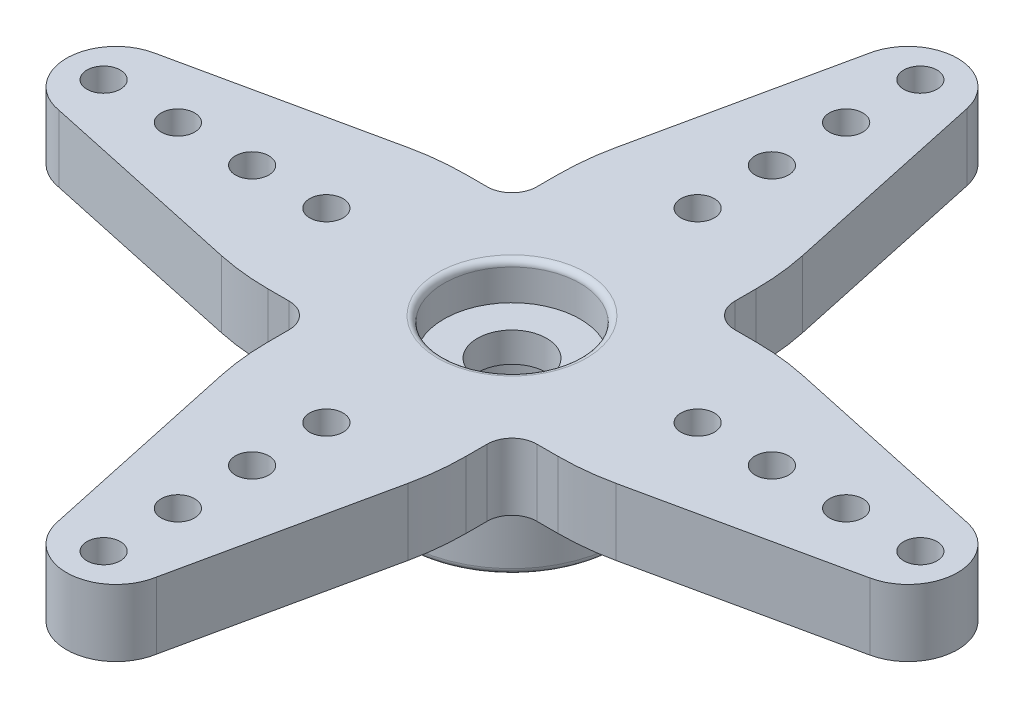
from build123d import *

# Parameters (mm, degrees)
ESQUISSE1_R             = 1.4
ESQUISSE1_R_2           = 0.675
BOSS_EXTRU_1_DEPTH      = 2.7
ESQUISSE2_R             = 2.75
ENL_V_MAT_EXTRU_1_DEPTH = 1.5
ESQUISSE3_R             = 4.4
ESQUISSE3_R_2           = 2.75
BOSS_EXTRU_2_DEPTH      = 3.3
CONG_1_R                = 0.25


with BuildPart() as part:
    # Esquisse1 → Boss.-Extru.1 (new body)
    with BuildSketch(Plane(origin=(0, 0, 0), x_dir=(1, 0, 0), z_dir=(0, 1, 0))):
        with BuildLine():
            Line((-4, 5.86229381), (-4, 5))
            ThreePointArc((-4, 5), (-4.292893219, 4.292893219), (-5, 4))
            Line((-5, 4), (-5.863381493, 4))
            ThreePointArc((-5.863381493, 4), (-6.922217369, 3.943785325), (-7.969148823, 3.775773317))
            Line((-7.969148823, 3.775773317), (-16.421153466, 1.955154663))
            ThreePointArc((-16.421153466, 1.955154663), (-17.999482643, -0.04548802), (-16.331804641, -1.972284381))
            Line((-16.331804641, -1.972284381), (-7.970163814, -3.77532015))
            ThreePointArc((-7.970163814, -3.77532015), (-6.922199111, -3.943671392), (-5.86229381, -4))
            Line((-5.86229381, -4), (-5, -4))
            ThreePointArc((-5, -4), (-4.292893219, -4.292893219), (-4, -5))
            Line((-4, -5), (-4, -5.863381493))
            ThreePointArc((-4, -5.863381493), (-3.943785325, -6.922217369), (-3.775773317, -7.969148823))
            Line((-3.775773317, -7.969148823), (-1.955154663, -16.421153466))
            ThreePointArc((-1.955154663, -16.421153466), (0.04548802, -17.999482643), (1.972284381, -16.331804641))
            Line((1.972284381, -16.331804641), (3.77532015, -7.970163814))
            ThreePointArc((3.77532015, -7.970163814), (3.943671392, -6.922199111), (4, -5.86229381))
            Line((4, -5.86229381), (4, -5))
            ThreePointArc((4, -5), (4.292893219, -4.292893219), (5, -4))
            Line((5, -4), (5.863381493, -4))
            ThreePointArc((5.863381493, -4), (6.922217369, -3.943785325), (7.969148823, -3.775773317))
            Line((7.969148823, -3.775773317), (16.421153466, -1.955154663))
            ThreePointArc((16.421153466, -1.955154663), (17.999482643, 0.04548802), (16.331804641, 1.972284381))
            Line((16.331804641, 1.972284381), (7.970163814, 3.77532015))
            ThreePointArc((7.970163814, 3.77532015), (6.922199111, 3.943671392), (5.86229381, 4))
            Line((5.86229381, 4), (5, 4))
            ThreePointArc((5, 4), (4.292893219, 4.292893219), (4, 5))
            Line((4, 5), (4, 5.863381493))
            ThreePointArc((4, 5.863381493), (3.943785325, 6.922217369), (3.775773317, 7.969148823))
            Line((3.775773317, 7.969148823), (1.955154663, 16.421153466))
            ThreePointArc((1.955154663, 16.421153466), (-0.04548802, 17.999482643), (-1.972284381, 16.331804641))
            Line((-1.972284381, 16.331804641), (-3.77532015, 7.970163814))
            ThreePointArc((-3.77532015, 7.970163814), (-3.943671392, 6.922199111), (-4, 5.86229381))
        make_face()
        Circle(ESQUISSE1_R, mode=Mode.SUBTRACT)
        with Locations((0, 16.5)):
            Circle(ESQUISSE1_R_2, mode=Mode.SUBTRACT)
        with Locations((0, 10.5)):
            Circle(ESQUISSE1_R_2, mode=Mode.SUBTRACT)
        with Locations((0, 7.5)):
            Circle(ESQUISSE1_R_2, mode=Mode.SUBTRACT)
        with Locations((0, 13.5)):
            Circle(ESQUISSE1_R_2, mode=Mode.SUBTRACT)
        with Locations((16.5, 0)):
            Circle(ESQUISSE1_R_2, mode=Mode.SUBTRACT)
        with Locations((13.5, 0)):
            Circle(ESQUISSE1_R_2, mode=Mode.SUBTRACT)
        with Locations((10.5, 0)):
            Circle(ESQUISSE1_R_2, mode=Mode.SUBTRACT)
        with Locations((7.5, 0)):
            Circle(ESQUISSE1_R_2, mode=Mode.SUBTRACT)
        with Locations((0, -16.5)):
            Circle(ESQUISSE1_R_2, mode=Mode.SUBTRACT)
        with Locations((0, -13.5)):
            Circle(ESQUISSE1_R_2, mode=Mode.SUBTRACT)
        with Locations((0, -10.5)):
            Circle(ESQUISSE1_R_2, mode=Mode.SUBTRACT)
        with Locations((0, -7.5)):
            Circle(ESQUISSE1_R_2, mode=Mode.SUBTRACT)
        with Locations((-16.5, 0)):
            Circle(ESQUISSE1_R_2, mode=Mode.SUBTRACT)
        with Locations((-13.5, 0)):
            Circle(ESQUISSE1_R_2, mode=Mode.SUBTRACT)
        with Locations((-10.5, 0)):
            Circle(ESQUISSE1_R_2, mode=Mode.SUBTRACT)
        with Locations((-7.5, 0)):
            Circle(ESQUISSE1_R_2, mode=Mode.SUBTRACT)
    extrude(amount=BOSS_EXTRU_1_DEPTH)

    # Esquisse2 → Enlèv. mat.-Extru.1 (cut)
    with BuildSketch(Plane(origin=(0, 2.7, 0), x_dir=(1, 0, 0), z_dir=(0, 1, 0))):
        Circle(ESQUISSE2_R)
    extrude(amount=-ENL_V_MAT_EXTRU_1_DEPTH, mode=Mode.SUBTRACT)

    # Esquisse3 → Boss.-Extru.2 (add)
    with BuildSketch(Plane.XZ):
        Circle(ESQUISSE3_R)
        Circle(ESQUISSE3_R_2, mode=Mode.SUBTRACT)
    extrude(amount=BOSS_EXTRU_2_DEPTH)

    # Congé1
    cong_1_edges = [part.edges().sort_by_distance(p)[0] for p in [
        (-2.75, 2.7, 0),
        (-4.4, -3.3, 0),
        (-2.75, -3.3, 0),
    ]]
    fillet(cong_1_edges, radius=CONG_1_R)


solid = part.part
